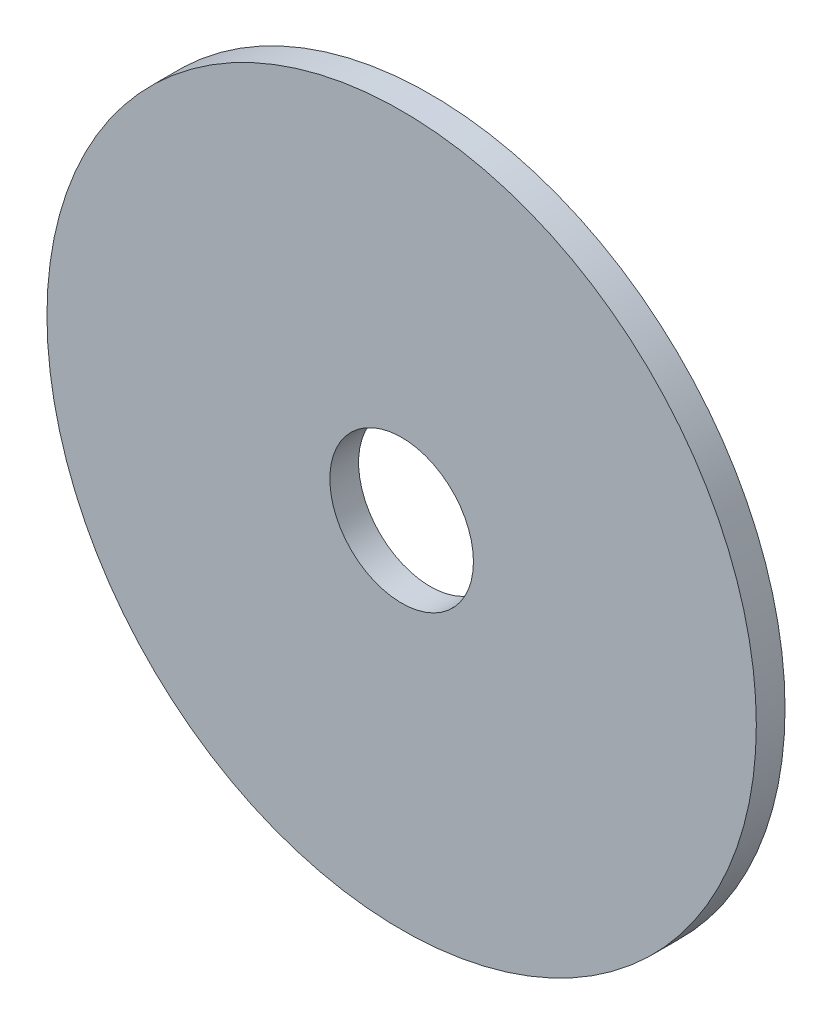
from build123d import *

# Parameters (mm, degrees)
SKETCH1_R           = 12.35
SKETCH1_R_2         = 2.5
BOSS_EXTRUDE1_DEPTH = 1


with BuildPart() as part:
    # Sketch1 → Boss-Extrude1 (new body)
    with BuildSketch(Plane.XY):
        Circle(SKETCH1_R)
        Circle(SKETCH1_R_2, mode=Mode.SUBTRACT)
    extrude(amount=BOSS_EXTRUDE1_DEPTH)


solid = part.part
